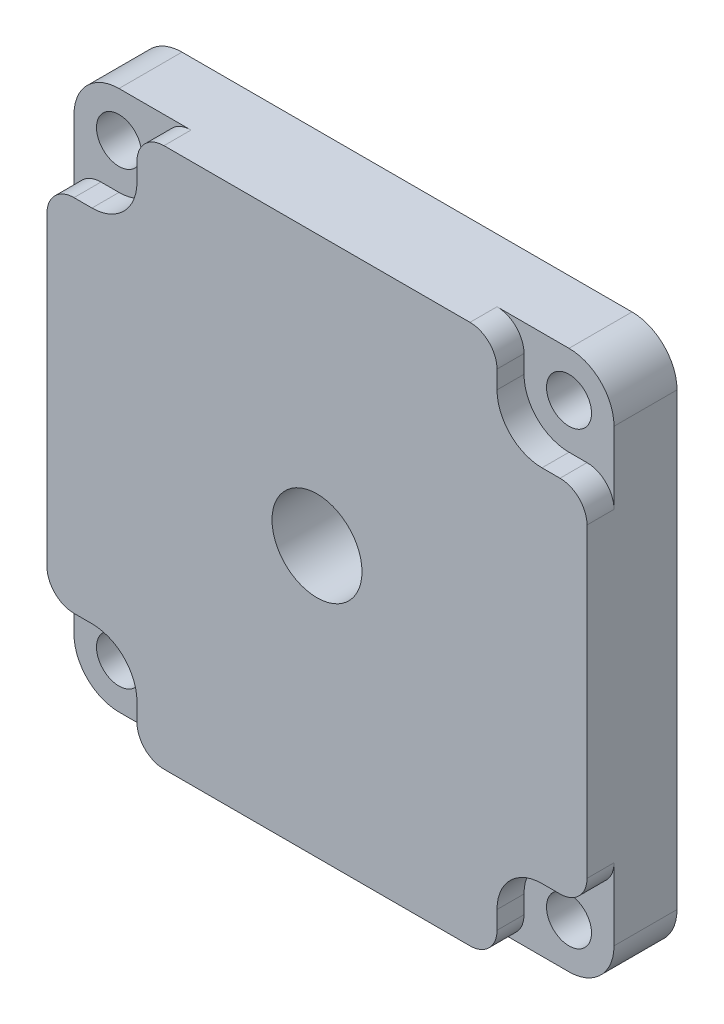
from build123d import *

# Parameters (mm, degrees)
IZIM1_R                     = 2.5
Y_KSEKLIK_EKSTR_ZYON1_DEPTH = 7
Y_KSEKLIK_EKSTR_ZYON2_DEPTH = 3
IZIM4_R                     = 19
Y_KSEKLIK_EKSTR_ZYON4_DEPTH = 1.2
RADYUS1_R                   = 0.5
IZIM6_R                     = 5
KES_EKSTR_ZYON2_DEPTH       = 12.2


with BuildPart() as part:
    # Çizim1 → Yükseklik-Ekstrüzyon1 (new body)
    with BuildSketch(Plane.XY):
        with BuildLine():
            Line((-28.709869289, 29.893846154), (21.290130711, 29.893846154))
            ThreePointArc((21.290130711, 29.893846154), (24.825664617, 28.42938006), (26.290130711, 24.893846154))
            Line((26.290130711, 24.893846154), (26.290130711, -25.106153846))
            ThreePointArc((26.290130711, -25.106153846), (24.825664617, -28.641687752), (21.290130711, -30.106153846))
            Line((21.290130711, -30.106153846), (-28.709869289, -30.106153846))
            ThreePointArc((-28.709869289, -30.106153846), (-32.245403195, -28.641687752), (-33.709869289, -25.106153846))
            Line((-33.709869289, -25.106153846), (-33.709869289, 24.893846154))
            ThreePointArc((-33.709869289, 24.893846154), (-32.245403195, 28.42938006), (-28.709869289, 29.893846154))
        make_face()
        with Locations((-28.709869289, 24.893846154)):
            Circle(IZIM1_R, mode=Mode.SUBTRACT)
        with Locations((21.290130711, 24.893846154)):
            Circle(IZIM1_R, mode=Mode.SUBTRACT)
        with Locations((21.290130711, -25.106153846)):
            Circle(IZIM1_R, mode=Mode.SUBTRACT)
        with Locations((-28.709869289, -25.106153846)):
            Circle(IZIM1_R, mode=Mode.SUBTRACT)
    extrude(amount=Y_KSEKLIK_EKSTR_ZYON1_DEPTH)

    # Çizim2 → Yükseklik-Ekstrüzyon2 (add)
    with BuildSketch(Plane.XY.offset(7)):
        with BuildLine():
            Line((13.290130711, 29.893846154), (-20.709869289, 29.893846154))
            ThreePointArc((-20.709869289, 29.893846154), (-22.831189632, 29.015166497), (-23.709869289, 26.893846154))
            Line((-23.709869289, 26.893846154), (-23.709869289, 24.893846154))
            ThreePointArc((-23.709869289, 24.893846154), (-25.174335383, 21.358312248), (-28.709869289, 19.893846154))
            Line((-28.709869289, 19.893846154), (-30.709869289, 19.893846154))
            ThreePointArc((-30.709869289, 19.893846154), (-32.831189632, 19.015166497), (-33.709869289, 16.893846154))
            Line((-33.709869289, 16.893846154), (-33.709869289, -17.106153846))
            ThreePointArc((-33.709869289, -17.106153846), (-32.831189632, -19.22747419), (-30.709869289, -20.106153846))
            Line((-30.709869289, -20.106153846), (-28.709869289, -20.106153846))
            ThreePointArc((-28.709869289, -20.106153846), (-25.174335383, -21.57061994), (-23.709869289, -25.106153846))
            Line((-23.709869289, -25.106153846), (-23.709869289, -27.106153846))
            ThreePointArc((-23.709869289, -27.106153846), (-22.831189632, -29.22747419), (-20.709869289, -30.106153846))
            Line((-20.709869289, -30.106153846), (13.290130711, -30.106153846))
            ThreePointArc((13.290130711, -30.106153846), (15.411451055, -29.22747419), (16.290130711, -27.106153846))
            Line((16.290130711, -27.106153846), (16.290130711, -25.106153846))
            ThreePointArc((16.290130711, -25.106153846), (17.754596805, -21.57061994), (21.290130711, -20.106153846))
            Line((21.290130711, -20.106153846), (23.290130711, -20.106153846))
            ThreePointArc((23.290130711, -20.106153846), (25.411451055, -19.22747419), (26.290130711, -17.106153846))
            Line((26.290130711, -17.106153846), (26.290130711, 16.893846154))
            ThreePointArc((26.290130711, 16.893846154), (25.411451055, 19.015166497), (23.290130711, 19.893846154))
            Line((23.290130711, 19.893846154), (21.290130711, 19.893846154))
            ThreePointArc((21.290130711, 19.893846154), (17.754596805, 21.358312248), (16.290130711, 24.893846154))
            Line((16.290130711, 24.893846154), (16.290130711, 26.893846154))
            ThreePointArc((16.290130711, 26.893846154), (15.411451055, 29.015166497), (13.290130711, 29.893846154))
        make_face()
    extrude(amount=Y_KSEKLIK_EKSTR_ZYON2_DEPTH)

    # Çizim4 → Yükseklik-Ekstrüzyon4 (add)
    with BuildSketch(Plane(origin=(0, 0, 0), x_dir=(-1, 0, 0), z_dir=(0, 0, -1))):
        with Locations((3.709869289, -0.106153846)):
            Circle(IZIM4_R)
    extrude(amount=Y_KSEKLIK_EKSTR_ZYON4_DEPTH)

    # Radyus1
    radyus1_edges = [part.edges().sort_by_distance(p)[0] for p in [
        (-31.209869289, 24.893846154, 0),
        (18.790130711, 24.893846154, 0),
        (18.790130711, -25.106153846, 0),
        (-31.209869289, -25.106153846, 0),
    ]]
    fillet(radyus1_edges, radius=RADYUS1_R)

    # Çizim6 → Kes-Ekstrüzyon2 (cut, through all)
    with BuildSketch(Plane(origin=(0, 0, -1.2), x_dir=(-1, 0, 0), z_dir=(0, 0, -1))):
        with Locations((3.709869289, -0.106153846)):
            Circle(IZIM6_R)
    extrude(amount=-KES_EKSTR_ZYON2_DEPTH, mode=Mode.SUBTRACT)


solid = part.part
